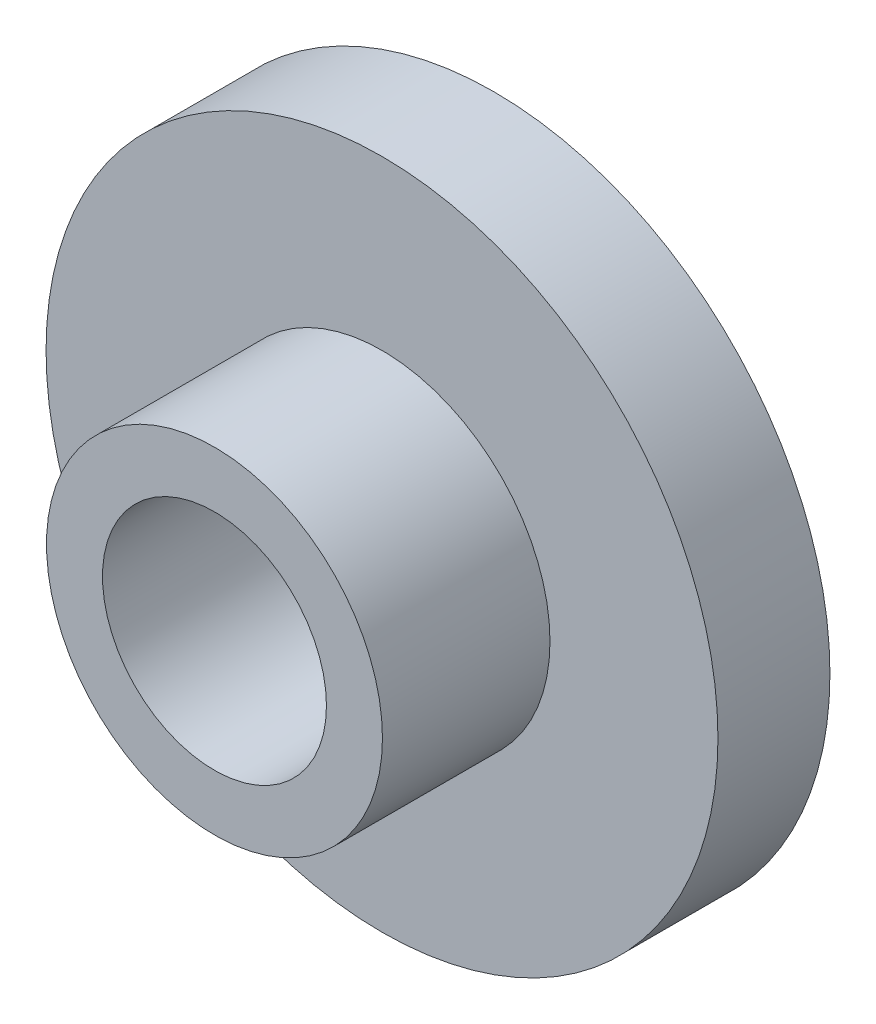
from build123d import *

# Parameters (mm, degrees)
SKETCH1_R           = 9.525
BOSS_EXTRUDE1_DEPTH = 3.175
SKETCH2_R           = 4.7625
BOSS_EXTRUDE2_DEPTH = 4.7498
SKETCH3_R           = 3.175
CUT_EXTRUDE1_DEPTH  = 7.9756


with BuildPart() as part:
    # Sketch1 → Boss-Extrude1 (new body)
    with BuildSketch(Plane.XY):
        Circle(SKETCH1_R)
    extrude(amount=BOSS_EXTRUDE1_DEPTH)

    # Sketch2 → Boss-Extrude2 (add)
    with BuildSketch(Plane.XY.offset(3.175)):
        Circle(SKETCH2_R)
    extrude(amount=BOSS_EXTRUDE2_DEPTH)

    # Sketch3 → Cut-Extrude1 (cut)
    with BuildSketch(Plane.XY.offset(7.9248)):
        Circle(SKETCH3_R)
    extrude(amount=-CUT_EXTRUDE1_DEPTH, mode=Mode.SUBTRACT)


solid = part.part
